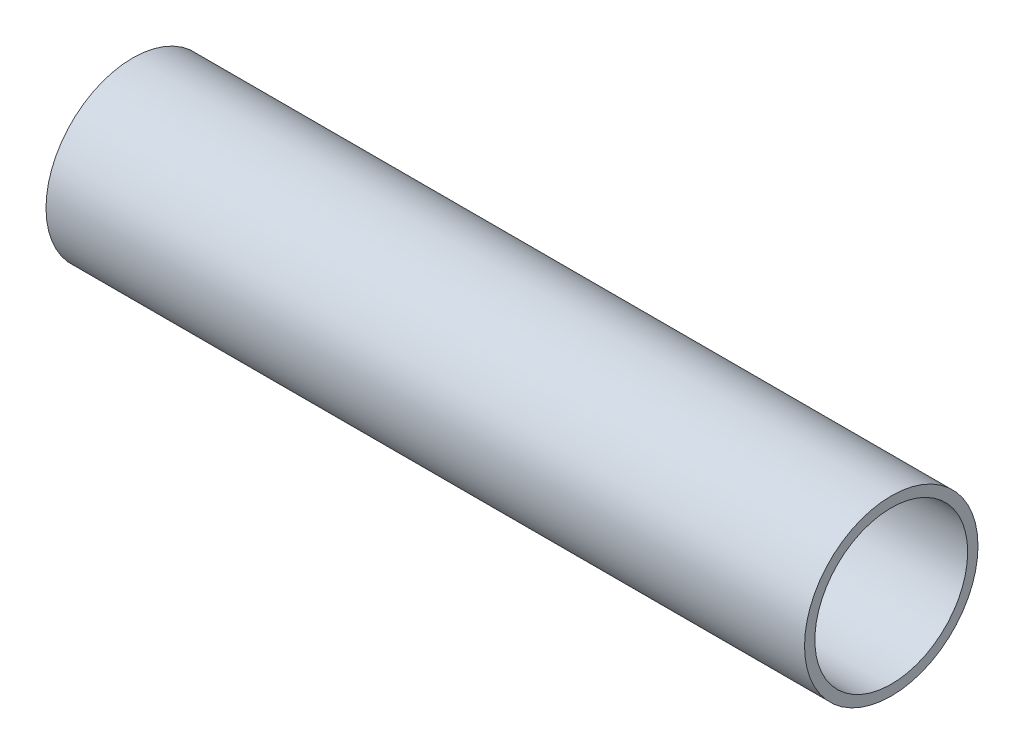
from build123d import *

# Parameters (mm, degrees)
SKETCH1_R           = 6.3
SKETCH1_R_2         = 5.55
EXTRUDE_THIN1_DEPTH = 55.1


with BuildPart() as part:
    # Sketch1 → Extrude-Thin1 (new body)
    with BuildSketch(Plane(origin=(0, 0, 0), x_dir=(0, 0, -1), z_dir=(1, 0, 0))):
        Circle(SKETCH1_R)
        Circle(SKETCH1_R_2, mode=Mode.SUBTRACT)
    extrude(amount=EXTRUDE_THIN1_DEPTH)


solid = part.part
